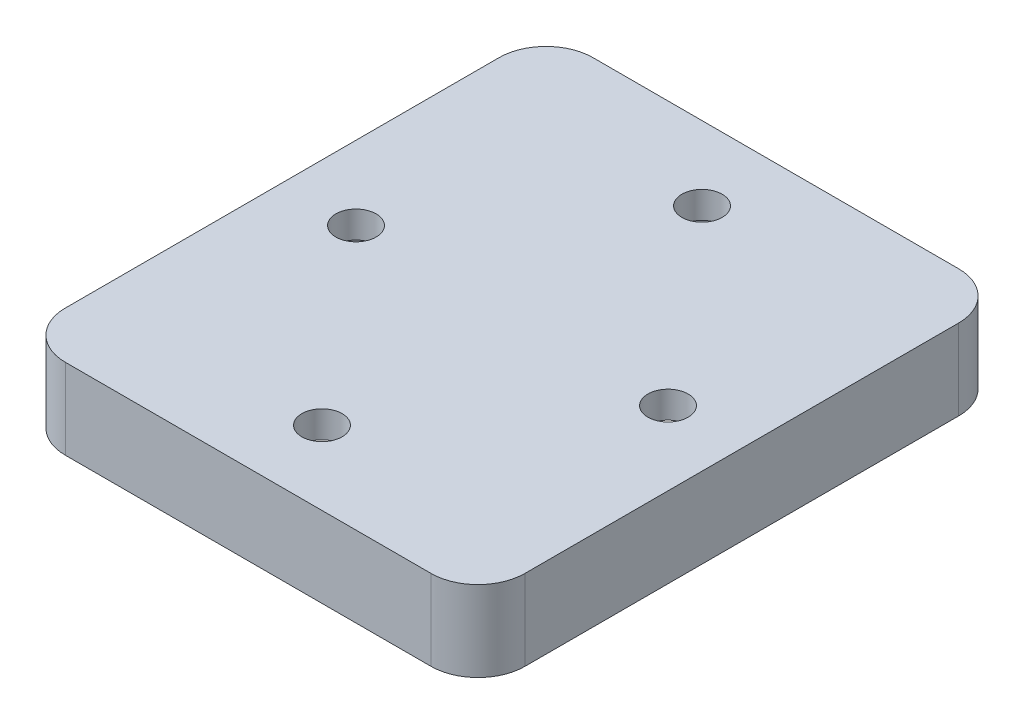
from build123d import *

# Parameters (mm, degrees)
SKETCH1_W           = 31.25
SKETCH1_H           = 36.32
SKETCH1_R           = 1.5
BOSS_EXTRUDE2_DEPTH = 2
FILLET1_R           = 2
BOSS_EXTRUDE3_DEPTH = 6


with BuildPart() as part:
    # Sketch1 → Boss-Extrude2 (new body)
    with BuildSketch(Plane(origin=(0, 0, 0), x_dir=(1, 0, 0), z_dir=(0, 1, 0))):
        with Locations((-0.273367395, -0.136683698)):
            Rectangle(SKETCH1_W, SKETCH1_H)
        with Locations((-0.273367395, 14.023316302)):
            Circle(SKETCH1_R, mode=Mode.SUBTRACT)
        with Locations((-11.898367395, -0.136683698)):
            Circle(SKETCH1_R, mode=Mode.SUBTRACT)
        with Locations((-0.273367395, -14.296683698)):
            Circle(SKETCH1_R, mode=Mode.SUBTRACT)
        with Locations((11.351632605, -0.136683698)):
            Circle(SKETCH1_R, mode=Mode.SUBTRACT)
    extrude(amount=BOSS_EXTRUDE2_DEPTH)

    # Fillet1
    fillet1_edges = [part.edges().sort_by_distance(p)[0] for p in [
        (15.351632605, 1, 18.296683698),
        (-15.898367395, 1, 18.296683698),
        (-15.898367395, 1, -18.023316302),
        (15.351632605, 1, -18.023316302),
    ]]
    fillet(fillet1_edges, radius=FILLET1_R)

    # Sketch3 → Boss-Extrude3 (add)
    with BuildSketch(Plane(origin=(0, 2, 0), x_dir=(1, 0, 0), z_dir=(0, 1, 0))):
        with BuildLine():
            Line((13.351632605, 19.523316302), (-13.898367395, 19.523316302))
            ThreePointArc((-13.898367395, 19.523316302), (-16.373241129, 18.498190037), (-17.398367395, 16.023316302))
            Line((-17.398367395, 16.023316302), (-17.398367395, -16.296683698))
            ThreePointArc((-17.398367395, -16.296683698), (-16.373241129, -18.771557432), (-13.898367395, -19.796683698))
            Line((-13.898367395, -19.796683698), (13.351632605, -19.796683698))
            ThreePointArc((13.351632605, -19.796683698), (15.826506339, -18.771557432), (16.851632605, -16.296683698))
            Line((16.851632605, -16.296683698), (16.851632605, 16.023316302))
            ThreePointArc((16.851632605, 16.023316302), (15.826506339, 18.498190037), (13.351632605, 19.523316302))
        make_face()
        with BuildLine():
            Line((13.351632605, 18.023316302), (-13.898367395, 18.023316302))
            ThreePointArc((-13.898367395, 18.023316302), (-15.312580957, 17.437529865), (-15.898367395, 16.023316302))
            Line((-15.898367395, 16.023316302), (-15.898367395, -16.296683698))
            ThreePointArc((-15.898367395, -16.296683698), (-15.312580957, -17.71089726), (-13.898367395, -18.296683698))
            Line((-13.898367395, -18.296683698), (13.351632605, -18.296683698))
            ThreePointArc((13.351632605, -18.296683698), (14.765846167, -17.71089726), (15.351632605, -16.296683698))
            Line((15.351632605, -16.296683698), (15.351632605, 16.023316302))
            ThreePointArc((15.351632605, 16.023316302), (14.765846167, 17.437529865), (13.351632605, 18.023316302))
        make_face(mode=Mode.SUBTRACT)
    extrude(amount=-BOSS_EXTRUDE3_DEPTH)


solid = part.part
